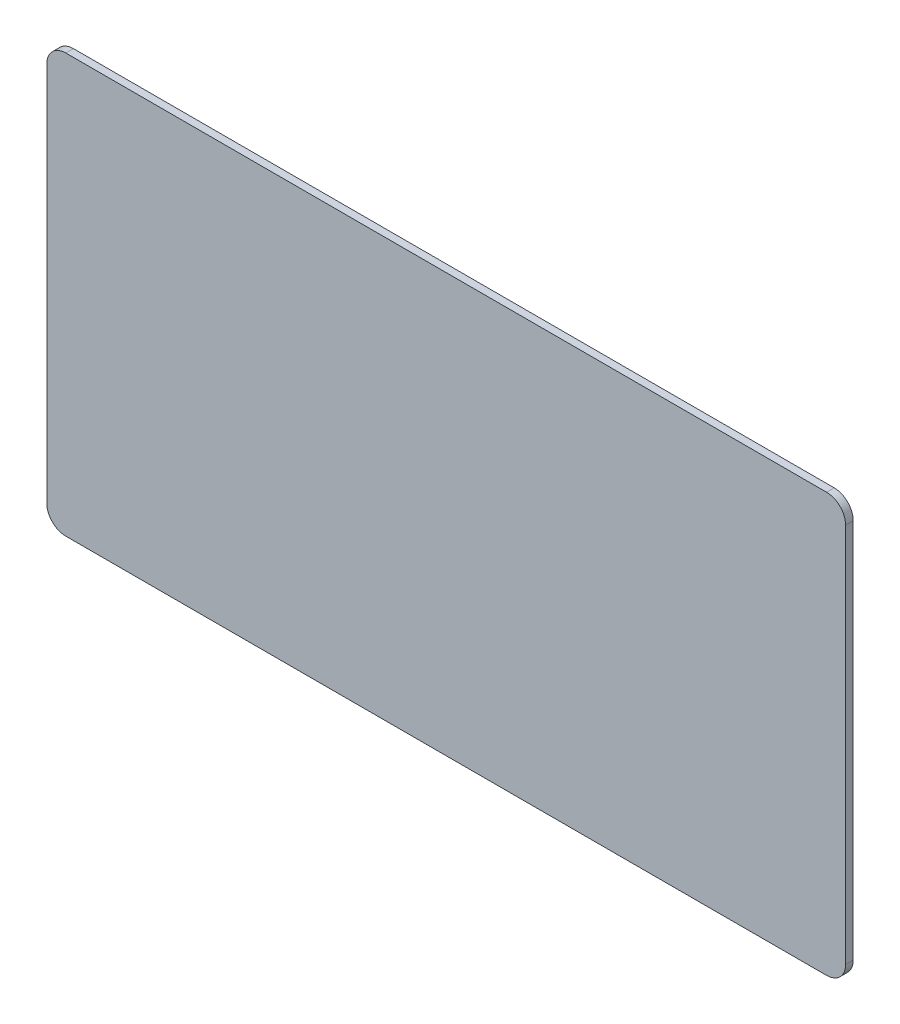
from build123d import *

# Parameters (mm, degrees)
SKETCH1_W      = 53.34
SKETCH1_H      = 27.94
EXTRUDE1_DEPTH = 0.508
FILLET1_R      = 1.27


with BuildPart() as part:
    # Sketch1 → Extrude1 (new body)
    with BuildSketch(Plane.XY):
        with Locations((26.67, 13.97)):
            Rectangle(SKETCH1_W, SKETCH1_H)
    extrude(amount=EXTRUDE1_DEPTH)

    # Fillet1
    fillet1_edges = [part.edges().sort_by_distance(p)[0] for p in [
        (0, 27.94, 0.254),
        (53.34, 27.94, 0.254),
        (53.34, 0, 0.254),
        (0, 0, 0.254),
    ]]
    fillet(fillet1_edges, radius=FILLET1_R)


solid = part.part
